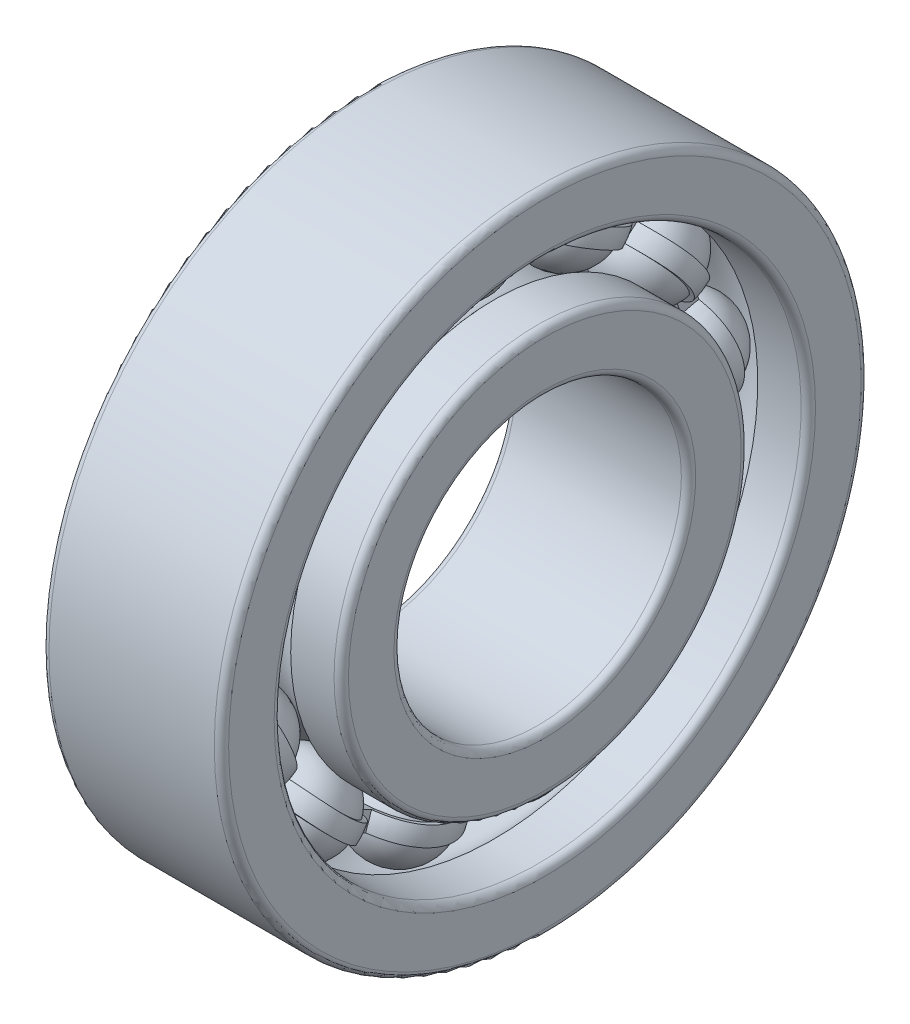
from build123d import *
from build123d.topology import SkipClean

# Parameters (mm, degrees)
SKETCH_5_W               = 0.375
SKETCH_5_H               = 0.25
PATTERN_CIRCULAR_5_COUNT = 13
PATTERN_CIRCULAR_2_COUNT = 13


with BuildPart() as part:
    # 草图2 → 旋转1 (revolve)
    with BuildSketch(Plane.XY, mode=Mode.PRIVATE) as revolve_1_sk:
        with BuildLine():
            Line((1.15, 2), (-1.15, 2))
            ThreePointArc((-1.15, 2), (-1.220710678, 2.029289322), (-1.25, 2.1))
            Line((-1.25, 2.1), (-1.25, 2.733333333))
            ThreePointArc((-1.25, 2.733333333), (-1.220710678, 2.804044011), (-1.15, 2.833333333))
            Line((-1.15, 2.833333333), (-0.465847495, 2.833333333))
            ThreePointArc((-0.465847495, 2.833333333), (0, 2.625), (0.465847495, 2.833333333))
            Line((0.465847495, 2.833333333), (1.15, 2.833333333))
            ThreePointArc((1.15, 2.833333333), (1.220710678, 2.804044011), (1.25, 2.733333333))
            Line((1.25, 2.733333333), (1.25, 2.1))
            ThreePointArc((1.25, 2.1), (1.220710678, 2.029289322), (1.15, 2))
        make_face()
        with BuildLine():
            Line((-1.25, 4.4), (-1.25, 3.766666667))
            ThreePointArc((-1.25, 3.766666667), (-1.220710678, 3.695955989), (-1.15, 3.666666667))
            Line((-1.15, 3.666666667), (-0.465847495, 3.666666667))
            ThreePointArc((-0.465847495, 3.666666667), (0, 3.875), (0.465847495, 3.666666667))
            Line((0.465847495, 3.666666667), (1.15, 3.666666667))
            ThreePointArc((1.15, 3.666666667), (1.220710678, 3.695955989), (1.25, 3.766666667))
            Line((1.25, 3.766666667), (1.25, 4.4))
            ThreePointArc((1.25, 4.4), (1.220710678, 4.470710678), (1.15, 4.5))
            Line((1.15, 4.5), (-1.15, 4.5))
            ThreePointArc((-1.15, 4.5), (-1.220710678, 4.470710678), (-1.25, 4.4))
        make_face()
    revolve(revolve_1_sk.sketch.rotate(Axis((-3.5, 0, 0), (1, 0, 0)), 90), axis=Axis((-3.5, 0, 0), (1, 0, 0)))


with BuildPart() as body_2:
    # 草图5 → 旋转3 (revolve)
    with BuildSketch(Plane.XY, mode=Mode.PRIVATE) as revolve_3_sk:
        with Locations((0, 3.25)):
            Rectangle(SKETCH_5_W, SKETCH_5_H)
    revolve(revolve_3_sk.sketch.rotate(Axis((-19.927092192, 0, 0), (1, 0, 0)), 90), axis=Axis((-19.927092192, 0, 0), (1, 0, 0)))



with BuildPart() as body_3:
    # 草图3 → 旋转2 (revolve)
    with BuildSketch(Plane.XY):
        with BuildLine():
            Line((-0.6875, 3.25), (0.6875, 3.25))
            ThreePointArc((0.6875, 3.25), (0, 3.9375), (-0.6875, 3.25))
        make_face()
    revolve(axis=Axis((-0.6875, 3.25, 0), (1, 0, 0)))


with BuildPart() as pattern_circular_5_1:
    # 阵列(圆周)5: pattern copy
    add(body_3.part.rotate(Axis((0, 0, 0), (1, 0, 0)), 1 * 360 / PATTERN_CIRCULAR_5_COUNT))


with BuildPart() as pattern_circular_5_2:
    # 阵列(圆周)5: pattern copy
    add(body_3.part.rotate(Axis((0, 0, 0), (1, 0, 0)), 2 * 360 / PATTERN_CIRCULAR_5_COUNT))


with BuildPart() as pattern_circular_5_3:
    # 阵列(圆周)5: pattern copy
    add(body_3.part.rotate(Axis((0, 0, 0), (1, 0, 0)), 3 * 360 / PATTERN_CIRCULAR_5_COUNT))


with BuildPart() as pattern_circular_5_4:
    # 阵列(圆周)5: pattern copy
    add(body_3.part.rotate(Axis((0, 0, 0), (1, 0, 0)), 4 * 360 / PATTERN_CIRCULAR_5_COUNT))


with BuildPart() as pattern_circular_5_5:
    # 阵列(圆周)5: pattern copy
    add(body_3.part.rotate(Axis((0, 0, 0), (1, 0, 0)), 5 * 360 / PATTERN_CIRCULAR_5_COUNT))


with BuildPart() as pattern_circular_5_6:
    # 阵列(圆周)5: pattern copy
    add(body_3.part.rotate(Axis((0, 0, 0), (1, 0, 0)), 6 * 360 / PATTERN_CIRCULAR_5_COUNT))


with BuildPart() as pattern_circular_5_7:
    # 阵列(圆周)5: pattern copy
    add(body_3.part.rotate(Axis((0, 0, 0), (1, 0, 0)), 7 * 360 / PATTERN_CIRCULAR_5_COUNT))


with BuildPart() as pattern_circular_5_8:
    # 阵列(圆周)5: pattern copy
    add(body_3.part.rotate(Axis((0, 0, 0), (1, 0, 0)), 8 * 360 / PATTERN_CIRCULAR_5_COUNT))


with BuildPart() as pattern_circular_5_9:
    # 阵列(圆周)5: pattern copy
    add(body_3.part.rotate(Axis((0, 0, 0), (1, 0, 0)), 9 * 360 / PATTERN_CIRCULAR_5_COUNT))


with BuildPart() as pattern_circular_5_10:
    # 阵列(圆周)5: pattern copy
    add(body_3.part.rotate(Axis((0, 0, 0), (1, 0, 0)), 10 * 360 / PATTERN_CIRCULAR_5_COUNT))


with BuildPart() as pattern_circular_5_11:
    # 阵列(圆周)5: pattern copy
    add(body_3.part.rotate(Axis((0, 0, 0), (1, 0, 0)), 11 * 360 / PATTERN_CIRCULAR_5_COUNT))


with BuildPart() as pattern_circular_5_12:
    # 阵列(圆周)5: pattern copy
    add(body_3.part.rotate(Axis((0, 0, 0), (1, 0, 0)), 12 * 360 / PATTERN_CIRCULAR_5_COUNT))


with BuildPart() as cut_revolve_1_tool:
    # 草图6 → 切除-旋转1 (revolve)
    with BuildSketch(Plane.XY):
        with BuildLine():
            Line((-0.676040864, 3.375), (0.676040864, 3.375))
            ThreePointArc((0.676040864, 3.375), (0, 3.9375), (-0.676040864, 3.375))
        make_face()
        with BuildLine():
            Line((-0.676040864, 3.125), (0.676040864, 3.125))
            ThreePointArc((0.676040864, 3.125), (0, 2.5625), (-0.676040864, 3.125))
        make_face()
    revolve(axis=Axis((-19.927092192, 0, 0), (1, 0, 0)))


with BuildPart() as part_1:
    add(part.part)

    # 切除-旋转1: cut by cut_revolve_1_tool
    add(cut_revolve_1_tool.part, mode=Mode.SUBTRACT)


with BuildPart() as body_3_1:
    add(body_3.part)

    # 切除-旋转1: cut by cut_revolve_1_tool
    add(cut_revolve_1_tool.part, mode=Mode.SUBTRACT)


with BuildPart() as pattern_circular_5_1_1:
    add(pattern_circular_5_1.part)

    # 切除-旋转1: cut by cut_revolve_1_tool
    add(cut_revolve_1_tool.part, mode=Mode.SUBTRACT)


with BuildPart() as pattern_circular_5_2_1:
    add(pattern_circular_5_2.part)

    # 切除-旋转1: cut by cut_revolve_1_tool
    add(cut_revolve_1_tool.part, mode=Mode.SUBTRACT)


with BuildPart() as pattern_circular_5_3_1:
    add(pattern_circular_5_3.part)

    # 切除-旋转1: cut by cut_revolve_1_tool
    add(cut_revolve_1_tool.part, mode=Mode.SUBTRACT)


with BuildPart() as pattern_circular_5_4_1:
    add(pattern_circular_5_4.part)

    # 切除-旋转1: cut by cut_revolve_1_tool
    add(cut_revolve_1_tool.part, mode=Mode.SUBTRACT)


with BuildPart() as pattern_circular_5_5_1:
    add(pattern_circular_5_5.part)

    # 切除-旋转1: cut by cut_revolve_1_tool
    add(cut_revolve_1_tool.part, mode=Mode.SUBTRACT)


with BuildPart() as pattern_circular_5_6_1:
    add(pattern_circular_5_6.part)

    # 切除-旋转1: cut by cut_revolve_1_tool
    add(cut_revolve_1_tool.part, mode=Mode.SUBTRACT)


with BuildPart() as pattern_circular_5_7_1:
    add(pattern_circular_5_7.part)

    # 切除-旋转1: cut by cut_revolve_1_tool
    add(cut_revolve_1_tool.part, mode=Mode.SUBTRACT)


with BuildPart() as pattern_circular_5_8_1:
    add(pattern_circular_5_8.part)

    # 切除-旋转1: cut by cut_revolve_1_tool
    add(cut_revolve_1_tool.part, mode=Mode.SUBTRACT)


with BuildPart() as pattern_circular_5_9_1:
    add(pattern_circular_5_9.part)

    # 切除-旋转1: cut by cut_revolve_1_tool
    add(cut_revolve_1_tool.part, mode=Mode.SUBTRACT)


with BuildPart() as pattern_circular_5_10_1:
    add(pattern_circular_5_10.part)

    # 切除-旋转1: cut by cut_revolve_1_tool
    add(cut_revolve_1_tool.part, mode=Mode.SUBTRACT)


with BuildPart() as pattern_circular_5_11_1:
    add(pattern_circular_5_11.part)

    # 切除-旋转1: cut by cut_revolve_1_tool
    add(cut_revolve_1_tool.part, mode=Mode.SUBTRACT)


with BuildPart() as pattern_circular_5_12_1:
    add(pattern_circular_5_12.part)

    # 切除-旋转1: cut by cut_revolve_1_tool
    add(cut_revolve_1_tool.part, mode=Mode.SUBTRACT)


with BuildPart() as body_2_1:
    with SkipClean():  # the faces are left unmerged after this step: merging them gives an invalid solid
        add(body_2.part)

        add(body_3_1.part)  # 旋转4 merges body 3
        # 草图7 → 旋转4 (revolve)
        with BuildSketch(Plane.XY):
            with BuildLine():
                Line((-0.625, 3.25), (0.625, 3.25))
                ThreePointArc((0.625, 3.25), (0, 3.875), (-0.625, 3.25))
            make_face()
        revolve_4 = revolve(axis=Axis((-0.625, 3.25, 0), (1, 0, 0)))

    # 阵列(圆周)2: 旋转4 ×13 about axis
    pattern_circular_2_axis = Axis((0, 0, 0), (1, 0, 0))
    for i in range(1, PATTERN_CIRCULAR_2_COUNT):
        add(revolve_4.rotate(pattern_circular_2_axis, i * 360 / PATTERN_CIRCULAR_2_COUNT))


solid = Compound([part_1.part, pattern_circular_5_1_1.part, pattern_circular_5_2_1.part, pattern_circular_5_3_1.part, pattern_circular_5_4_1.part, pattern_circular_5_5_1.part, pattern_circular_5_6_1.part, pattern_circular_5_7_1.part, pattern_circular_5_8_1.part, pattern_circular_5_9_1.part, pattern_circular_5_10_1.part, pattern_circular_5_11_1.part, pattern_circular_5_12_1.part, body_2_1.part])
